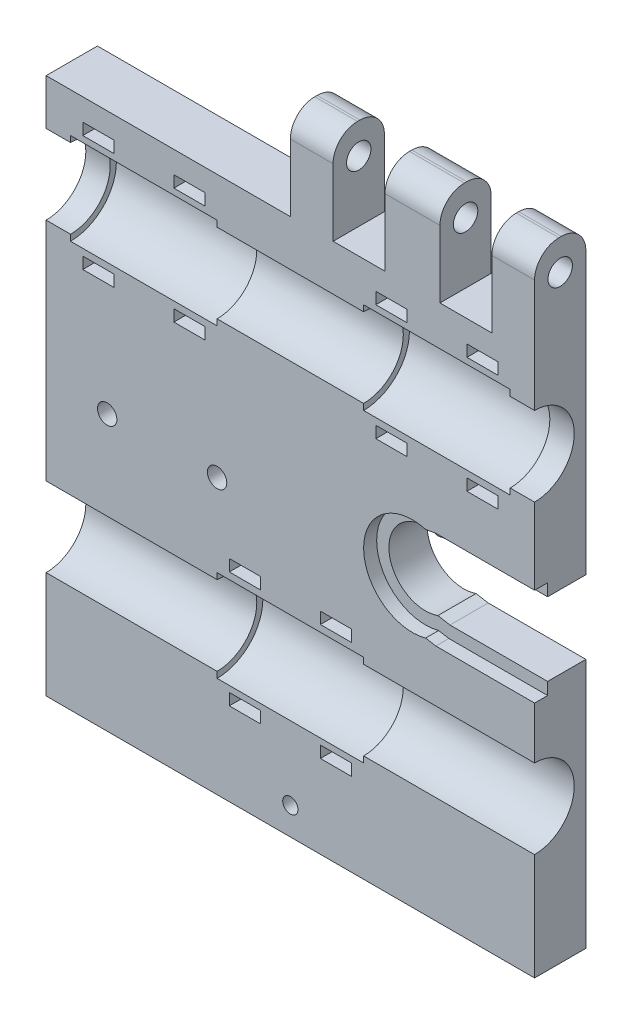
from build123d import *

# Parameters (mm, degrees)
SKETCH1_W                      = 80
SKETCH1_H                      = 78
BOSS_EXTRUDE1_DEPTH            = 8.4
SKETCH4_W                      = 5.08
SKETCH4_H                      = 1.905
CUT_EXTRUDE1_DEPTH             = 9.4
LPATTERN1_COUNT                = 2
LPATTERN1_PITCH                = 19
LPATTERN1_COUNT_DIR2           = 2
LPATTERN1_PITCH_DIR2           = 48
SKETCH5_W                      = 5.08
SKETCH5_H                      = 1.905
CUT_EXTRUDE2_DEPTH             = 8.4
LPATTERN2_COUNT                = 2
LPATTERN2_PITCH                = 19
CUT_EXTRUDE3_DEPTH             = 9.4
CUT_EXTRUDE4_DEPTH             = 2.138
SKETCH9_R                      = 1.5875
CUT_EXTRUDE5_DEPTH             = 9.4
SKETCH11_W                     = 80
SKETCH11_H                     = 8.4
BOSS_EXTRUDE3_DEPTH            = 10
F_2_5_2_5_DIAMETER_HOLE1_D     = 2.5
F_2_5_2_5_DIAMETER_HOLE1_DEPTH = 10
SKETCH14_W                     = 9
SKETCH14_H                     = 8.4
SKETCH14_W_2                   = 7
BOSS_EXTRUDE4_DEPTH            = 15
SKETCH16_R                     = 2
CUT_EXTRUDE6_DEPTH             = 45.4
FILLET1_R                      = 4


with BuildPart() as part:
    # Sketch1 → Boss-Extrude1 (new body)
    with BuildSketch(Plane.XY):
        with Locations((40, 39)):
            Rectangle(SKETCH1_W, SKETCH1_H)
    extrude(amount=BOSS_EXTRUDE1_DEPTH)

    # Sketch2 → Cut-Revolve1 (revolve, cut)
    with BuildSketch(Plane.XY.offset(8.4)):
        Polygon((0, 70.5), (0, 64), (9.541087991, 64), (23.495378694, 64), (54.462434776, 64), (68.225570813, 64), (80, 64), (80, 70.5), (76, 70.5), (76, 71.5), (52, 71.5), (52, 70.5), (28, 70.5), (28, 71.5), (4, 71.5), (4, 70.5), align=None)
    revolve(axis=Axis((0, 64, 8.4), (1, 0, 0)), mode=Mode.SUBTRACT)

    # Sketch3 → Cut-Revolve2 (revolve, cut)
    with BuildSketch(Plane.XY.offset(8.4)):
        Polygon((0, 20.5), (0, 14), (25.709253363, 14), (47.957380272, 14), (80, 14), (80, 20.5), (52, 20.5), (52, 21.5), (28, 21.5), (28, 20.5), align=None)
    revolve(axis=Axis((0, 14, 8.4), (1, 0, 0)), mode=Mode.SUBTRACT)

    # Sketch4 → Cut-Extrude1 (cut, through all)
    with BuildSketch(Plane.XY.offset(8.4)):
        with Locations((8.54, 73.4525)):
            Rectangle(SKETCH4_W, SKETCH4_H)
        with Locations((23.46, 73.4525)):
            Rectangle(SKETCH4_W, SKETCH4_H)
    cut_extrude1 = extrude(amount=-CUT_EXTRUDE1_DEPTH, mode=Mode.SUBTRACT)

    # LPattern1: Cut-Extrude1 2 × 2
    with Locations(*[(j * LPATTERN1_PITCH_DIR2, -i * LPATTERN1_PITCH, 0) for i in range(LPATTERN1_COUNT) for j in range(LPATTERN1_COUNT_DIR2) if (i, j) != (0, 0)]):
        add(cut_extrude1, mode=Mode.SUBTRACT)

    # Sketch5 → Cut-Extrude2 (cut)
    with BuildSketch(Plane.XY.offset(8.4)):
        with Locations((32.54, 23.5525)):
            Rectangle(SKETCH5_W, SKETCH5_H)
        with Locations((47.46, 23.5525)):
            Rectangle(SKETCH5_W, SKETCH5_H)
    cut_extrude2 = extrude(amount=-CUT_EXTRUDE2_DEPTH, mode=Mode.SUBTRACT)

    # LPattern2: Cut-Extrude2 ×2
    with Locations(*[(0, -i * LPATTERN2_PITCH, 0) for i in range(1, LPATTERN2_COUNT)]):
        add(cut_extrude2, mode=Mode.SUBTRACT)

    # Sketch6 → Cut-Extrude3 (cut, through all)
    with BuildSketch(Plane.XY.offset(8.4)):
        with BuildLine():
            ThreePointArc((62.017883983, 42.650499467), (61.02396367, 42.911979229), (60, 43))
            ThreePointArc((60, 43), (54, 37), (60, 31))
            ThreePointArc((60, 31), (61.02396367, 31.088020771), (62.017883983, 31.349500533))
            Line((62.017883983, 31.349500533), (64, 31))
            Line((64, 31), (80, 31))
            Line((80, 31), (80, 43))
            Line((80, 43), (64, 43))
            Line((64, 43), (62.017883983, 42.650499467))
        make_face()
    extrude(amount=-CUT_EXTRUDE3_DEPTH, mode=Mode.SUBTRACT)

    # Sketch8 → Cut-Extrude4 (cut)
    with BuildSketch(Plane.XY.offset(8.4)):
        with BuildLine():
            Line((80, 45), (80, 29))
            Line((80, 29), (63.825022673, 29))
            Line((63.825022673, 29), (62.152264354, 29.294952424))
            ThreePointArc((62.152264354, 29.294952424), (52, 37), (62.152264354, 44.705047576))
            Line((62.152264354, 44.705047576), (63.825022673, 45))
            Line((63.825022673, 45), (80, 45))
        make_face()
    extrude(amount=-CUT_EXTRUDE4_DEPTH, mode=Mode.SUBTRACT)

    # Sketch9 → Cut-Extrude5 (cut, through all)
    with BuildSketch(Plane.XY.offset(8.4)):
        with Locations((10, 35)):
            Circle(SKETCH9_R)
        with Locations((28, 35)):
            Circle(SKETCH9_R)
    extrude(amount=-CUT_EXTRUDE5_DEPTH, mode=Mode.SUBTRACT)

    # Sketch11 → Boss-Extrude3 (add)
    with BuildSketch(Plane(origin=(0, 0, 0), x_dir=(-1, 0, 0), z_dir=(0, -1, 0))):
        with Locations((-40, -4.2)):
            Rectangle(SKETCH11_W, SKETCH11_H)
    extrude(amount=BOSS_EXTRUDE3_DEPTH)

    # Ø2.5 (2.5) Diameter Hole1
    with Locations(Plane.XY.offset(8.4)):
        with Locations((40, -5.5)):
            Hole(F_2_5_2_5_DIAMETER_HOLE1_D / 2, depth=F_2_5_2_5_DIAMETER_HOLE1_DEPTH)

    # Sketch14 → Boss-Extrude4 (add)
    with BuildSketch(Plane(origin=(0, 78, 0), x_dir=(1, 0, 0), z_dir=(0, 1, 0))):
        with Locations((60, -4.2)):
            Rectangle(SKETCH14_W, SKETCH14_H)
        with Locations((76.5, -4.2)):
            Rectangle(SKETCH14_W_2, SKETCH14_H)
        with Locations((43.5, -4.2)):
            Rectangle(SKETCH14_W_2, SKETCH14_H)
    extrude(amount=BOSS_EXTRUDE4_DEPTH)

    # Sketch16 → Cut-Extrude6 (cut)
    with BuildSketch(Plane.ZY.offset(-40)):
        with Locations((4.2, 88)):
            Circle(SKETCH16_R)
    extrude(amount=-CUT_EXTRUDE6_DEPTH, mode=Mode.SUBTRACT)

    # Fillet1
    fillet1_edges = [part.edges().sort_by_distance(p)[0] for p in [
        (76.5, 93, 8.4),
        (76.5, 93, 0),
        (60, 93, 8.4),
        (60, 93, 0),
        (43.5, 93, 8.4),
        (43.5, 93, 0),
    ]]
    fillet(fillet1_edges, radius=FILLET1_R)


solid = part.part
